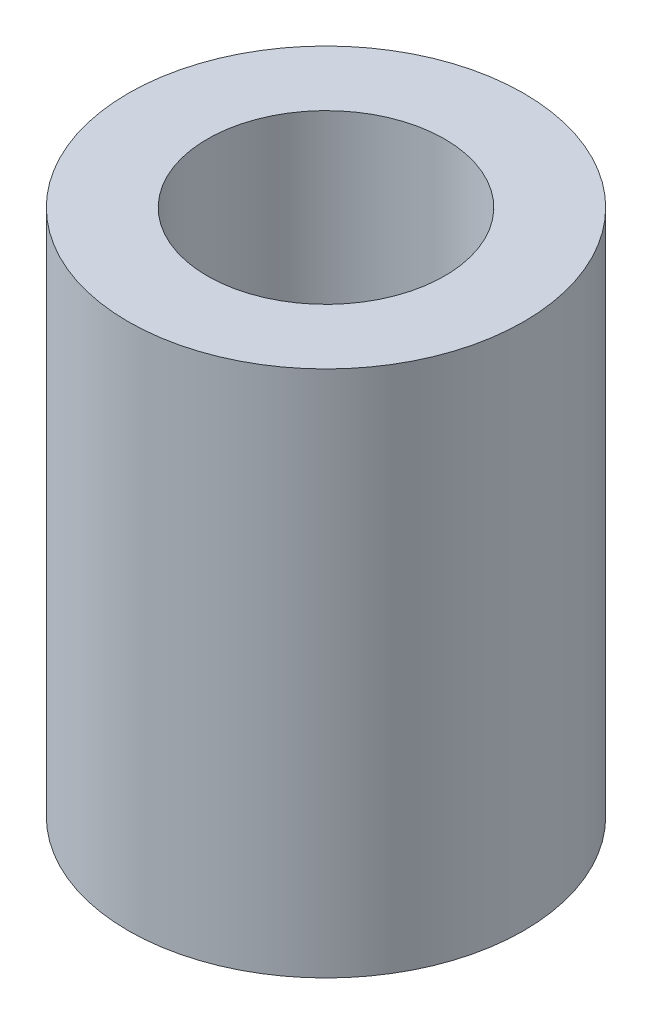
from build123d import *

# Parameters (mm, degrees)
SKETCH1_R           = 2.25
SKETCH1_R_2         = 1.35
BOSS_EXTRUDE1_DEPTH = 6


with BuildPart() as part:
    # Sketch1 → Boss-Extrude1 (new body)
    with BuildSketch(Plane(origin=(0, 0, 0), x_dir=(1, 0, 0), z_dir=(0, 1, 0))):
        with Locations(Location((0, 0, 0), (0, 0, 270))):  # turned: the seam where the file's is
            Circle(SKETCH1_R)
        with Locations(Location((0, 0, 0), (0, 0, 270))):  # turned: the seam where the file's is
            Circle(SKETCH1_R_2, mode=Mode.SUBTRACT)
    extrude(amount=BOSS_EXTRUDE1_DEPTH)


solid = part.part
